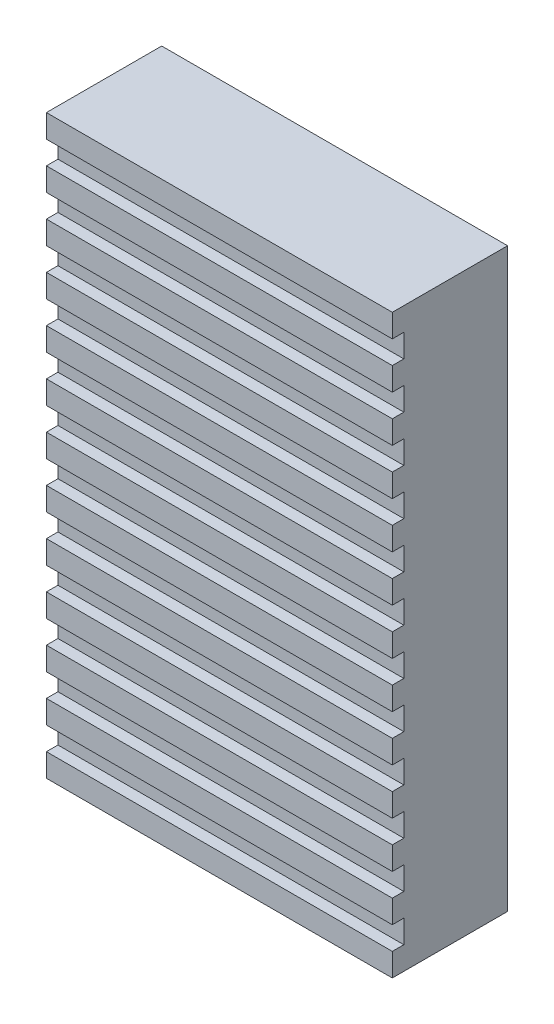
from build123d import *

# Parameters (mm, degrees)
SKETCH1_W           = 30
SKETCH1_H           = 50
BOSS_EXTRUDE1_DEPTH = 10
SKETCH2_W           = 30
SKETCH2_H           = 2
CUT_EXTRUDE3_DEPTH  = 1


with BuildPart() as part:
    # Sketch1 → Boss-Extrude1 (new body)
    with BuildSketch(Plane.XY):
        with Locations((-15, -25)):
            Rectangle(SKETCH1_W, SKETCH1_H)
    extrude(amount=BOSS_EXTRUDE1_DEPTH)

    # Sketch2 → Cut-Extrude3 (cut)
    with BuildSketch(Plane.XY.offset(10)):
        with Locations((-15, -3)):
            Rectangle(SKETCH2_W, SKETCH2_H)
        with Locations((-15, -7)):
            Rectangle(SKETCH2_W, SKETCH2_H)
        with Locations((-15, -11)):
            Rectangle(SKETCH2_W, SKETCH2_H)
        with Locations((-15, -15)):
            Rectangle(SKETCH2_W, SKETCH2_H)
        with Locations((-15, -19)):
            Rectangle(SKETCH2_W, SKETCH2_H)
        with Locations((-15, -23)):
            Rectangle(SKETCH2_W, SKETCH2_H)
        with Locations((-15, -27)):
            Rectangle(SKETCH2_W, SKETCH2_H)
        with Locations((-15, -31)):
            Rectangle(SKETCH2_W, SKETCH2_H)
        with Locations((-15, -35)):
            Rectangle(SKETCH2_W, SKETCH2_H)
        with Locations((-15, -39)):
            Rectangle(SKETCH2_W, SKETCH2_H)
        with Locations((-15, -43)):
            Rectangle(SKETCH2_W, SKETCH2_H)
        with Locations((-15, -47)):
            Rectangle(SKETCH2_W, SKETCH2_H)
    extrude(amount=-CUT_EXTRUDE3_DEPTH, mode=Mode.SUBTRACT)


solid = part.part
